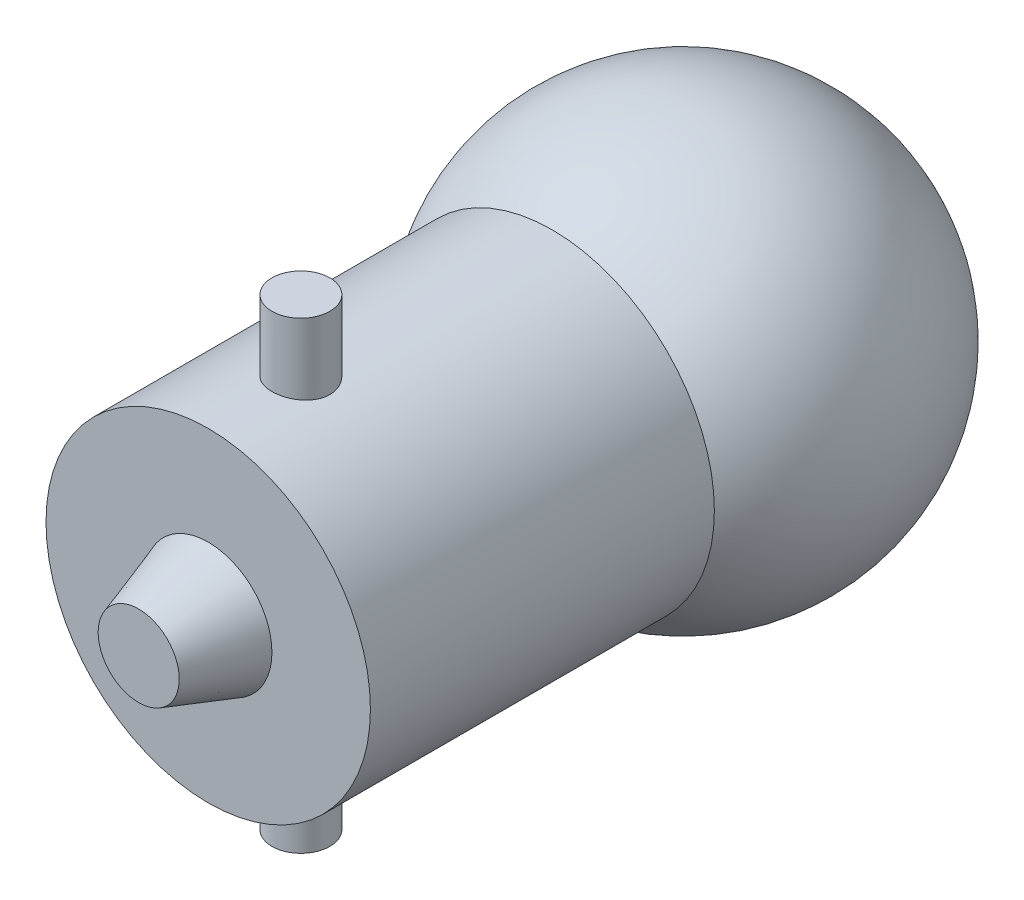
from build123d import *

# Parameters (mm, degrees)
ESQUISSE1_R        = 7
CORPS_DEPTH        = 15
ESQUISSE4_R        = 1.25
BAILLONETTES_DEPTH = 10


with BuildPart() as part:
    # Esquisse1 → Corps (new body)
    with BuildSketch(Plane.XY):
        with Locations(Location((0, 0, 0), (0, 0, 180))):  # turned: the seam where the file's is
            Circle(ESQUISSE1_R)
    extrude(amount=CORPS_DEPTH)

    # Esquisse3 → Verre (revolve)
    with BuildSketch(Plane(origin=(0, 0, 0), x_dir=(0, 0, -1), z_dir=(1, 0, 0))):
        with BuildLine():
            Line((5.5, -9), (5.5, 9))
            ThreePointArc((5.5, 9), (14.5, 0), (5.5, -9))
        make_face()
    revolve(axis=Axis((0, 11.000458592, -5.5), (0, -1, 0)))

    # Esquisse4 → Baillonettes (add, symmetric)
    with BuildSketch(Plane(origin=(0, 0, 0), x_dir=(1, 0, 0), z_dir=(0, 1, 0))):
        with Locations(Location((0, -11, 0), (0, 0, 90))):  # turned: the seam where the file's is
            Circle(ESQUISSE4_R)
    extrude(amount=BAILLONETTES_DEPTH, both=True)

    # Esquisse5 → Culot (revolve)
    with BuildSketch(Plane(origin=(0, 0, 0), x_dir=(0, 0, -1), z_dir=(1, 0, 0)), mode=Mode.PRIVATE) as culot_sk:
        Polygon((-18, 0), (-18, 1.75), (-15, 2.75), (-15, 0), align=None)
    revolve(culot_sk.sketch.rotate(Axis((0, 0, 9.557270233), (0, 0, 1)), 90), axis=Axis((0, 0, 9.557270233), (0, 0, 1)))  # turned: the seam where the file's is


solid = part.part
